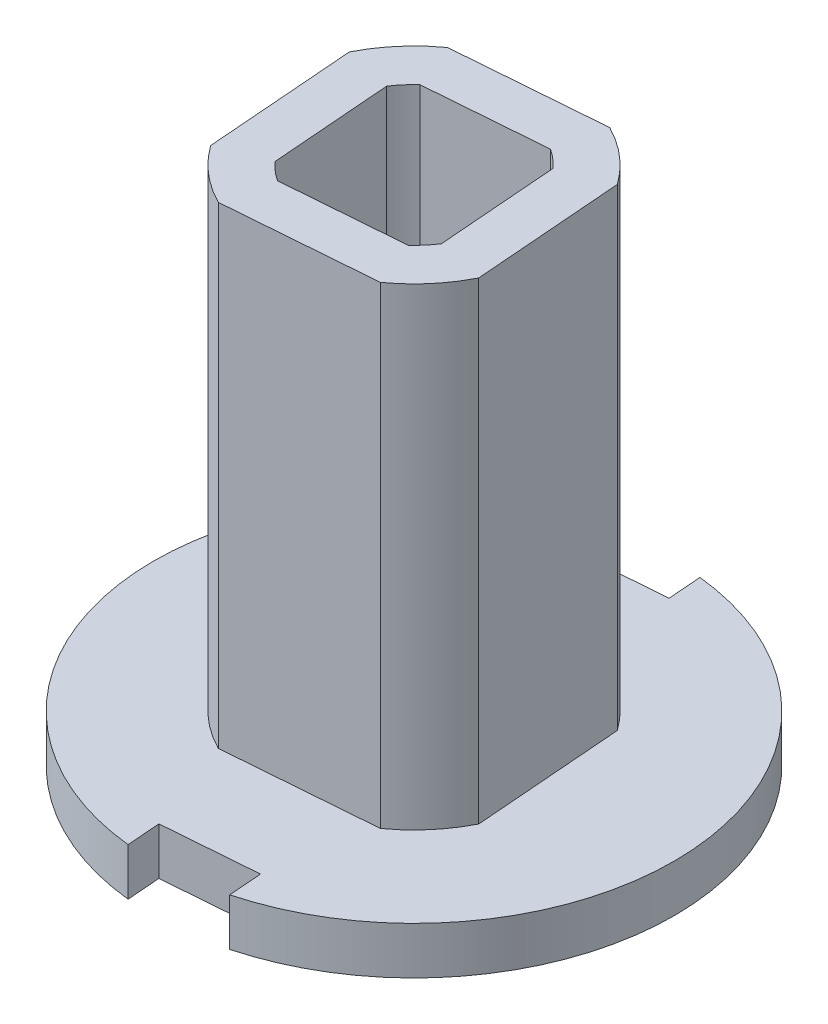
from build123d import *

# Parameters (mm, degrees)
BOSS_EXTRUDE1_DEPTH = 1
BOSS_EXTRUDE2_DEPTH = 10


with BuildPart() as part:
    # Sketch1 → Boss-Extrude1 (new body)
    with BuildSketch(Plane(origin=(0, 125.994845224, 0), x_dir=(0.9999961031753525, 0, 0.0027917080989731807), z_dir=(0, -1, 0))):
        with BuildLine():
            Line((-0.618086487, 4.765287934), (-0.561019037, 5.471312241))
            ThreePointArc((-0.561019037, 5.471312241), (-5.482120778, 0.443115979), (-1.432479428, -5.310179158))
            Line((-1.432479428, -5.310179158), (-1.375411978, -4.604154851))
            Line((-1.375411978, -4.604154851), (0.618086487, -4.765287934))
            Line((0.618086487, -4.765287934), (0.561019037, -5.471312241))
            ThreePointArc((0.561019037, -5.471312241), (5.482120778, -0.443115979), (1.432479428, 5.310179158))
            Line((1.432479428, 5.310179158), (1.375411978, 4.604154851))
            Line((1.375411978, 4.604154851), (-0.618086487, 4.765287934))
        make_face()
    extrude(amount=BOSS_EXTRUDE1_DEPTH)

    # Sketch1_4 → Boss-Extrude2 (add)
    with BuildSketch(Plane(origin=(0, 125.994845224, 0), x_dir=(0.9999961031753525, 0, 0.0027917080989731807), z_dir=(0, -1, 0))):
        with BuildLine():
            ThreePointArc((-2.757386609, -1.376787234), (-2.347797606, -1.996639778), (-1.801775741, -2.500465592))
            Line((-1.801775741, -2.500465592), (1.376787234, -2.757386609))
            ThreePointArc((1.376787234, -2.757386609), (1.996639778, -2.347797606), (2.500465592, -1.801775741))
            Line((2.500465592, -1.801775741), (2.628926101, -0.212494254))
            Line((2.628926101, -0.212494254), (2.757386609, 1.376787234))
            ThreePointArc((2.757386609, 1.376787234), (2.347797606, 1.996639778), (1.801775741, 2.500465592))
            Line((1.801775741, 2.500465592), (-1.376787234, 2.757386609))
            ThreePointArc((-1.376787234, 2.757386609), (-1.996639778, 2.347797606), (-2.500465592, 1.801775741))
            Line((-2.500465592, 1.801775741), (-2.628926101, 0.212494254))
            Line((-2.628926101, 0.212494254), (-2.757386609, -1.376787234))
        make_face()
        with BuildLine():
            Line((1.735770459, 1.149706447), (1.632176868, -0.131927712))
            Line((1.632176868, -0.131927712), (1.528583278, -1.413561871))
            ThreePointArc((1.528583278, -1.413561871), (1.348800784, -1.586020316), (1.149706447, -1.735770459))
            Line((1.149706447, -1.735770459), (-1.413561871, -1.528583278))
            ThreePointArc((-1.413561871, -1.528583278), (-1.586020316, -1.348800784), (-1.735770459, -1.149706447))
            Line((-1.735770459, -1.149706447), (-1.632176868, 0.131927712))
            Line((-1.632176868, 0.131927712), (-1.528583278, 1.413561871))
            ThreePointArc((-1.528583278, 1.413561871), (-1.348800784, 1.586020316), (-1.149706447, 1.735770459))
            Line((-1.149706447, 1.735770459), (1.413561871, 1.528583278))
            ThreePointArc((1.413561871, 1.528583278), (1.586020316, 1.348800784), (1.735770459, 1.149706447))
        make_face(mode=Mode.SUBTRACT)
    extrude(amount=-BOSS_EXTRUDE2_DEPTH)


solid = part.part
